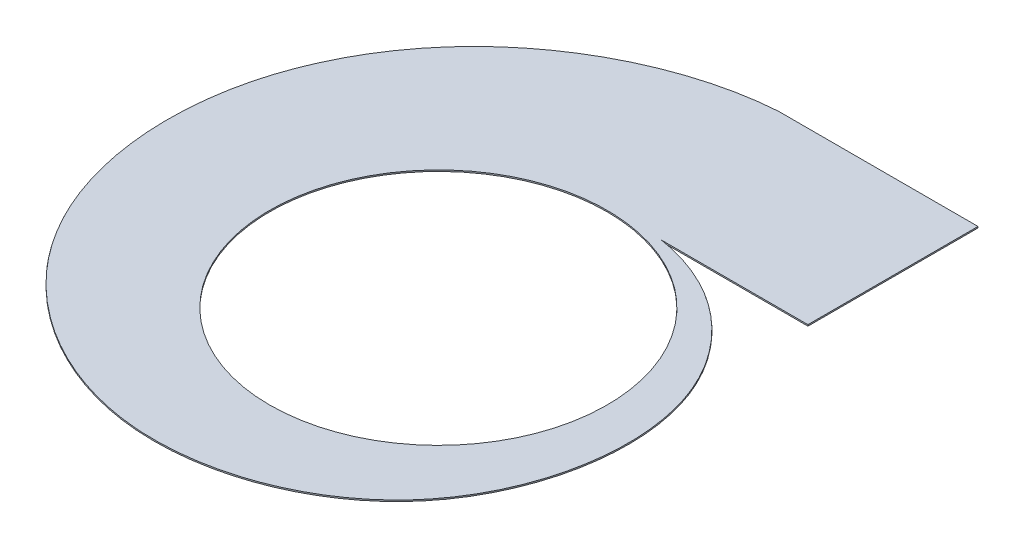
from build123d import *

# Parameters (mm, degrees)
SKETCH4_W               = 2
SKETCH4_H               = 200
BOSS_EXTRUDE1_DEPTH     = 2
SKETCH6_W               = 1405.005943927
SKETCH6_H               = 405.322926854
CUT_EXTRUDE1_DEPTH      = 315.996533231
CUT_EXTRUDE1_DEPTH_BACK = 440.29577895
SKETCH7_R               = 248
CUT_EXTRUDE2_DEPTH      = 10
SKETCH9_W               = 293.259068653
SKETCH9_H               = 250
BOSS_EXTRUDE3_DEPTH     = 2


with BuildPart() as part:
    # Sweep1: sweep along a curve in space
    with BuildLine() as sweep1_path:
        add(Edge.make_bspline(
            [(0, 0, -250), (8.181230869, 0, -251.302083333), (16.490485858, 0, -252.202239115), (33.283843215, 0, -253.165004898), (41.767918014, 0, -253.227597369), (58.825529276, 0, -252.489812839), (67.399036198, 0, -251.689421172), (84.546849552, 0, -249.209035813), (93.121124768, 0, -247.529030536), (110.179448676, 0, -243.28197111), (118.663464802, 0, -240.714908644), (135.448838644, 0, -234.695772919), (143.750162786, 0, -231.243694762), (160.077308396, 0, -223.466249466), (168.103095642, 0, -219.140880964), (183.786929167, 0, -209.638354886), (191.44494095, 0, -204.461199558), (206.302623467, 0, -193.286364859), (213.502259812, 0, -187.288691386), (227.355264371, 0, -174.513728488), (234.008598689, 0, -167.736448609), (246.684770924, 0, -153.452592355), (252.707575824, 0, -145.946029132), (264.043165005, 0, -130.262996352), (269.35591753, 0, -122.086543468), (279.197554898, 0, -105.131744499), (283.726409621, 0, -96.353418486), (291.933011092, 0, -78.270957675), (295.610729717, 0, -68.966846184), (302.055300528, 0, -49.916318794), (304.822126933, 0, -40.169929234), (309.39344656, 0, -20.325024564), (311.197916667, 0, -10.226538586), (313.802083333, 0, 10.226538586), (314.601759746, 0, 20.581098128), (315.163575101, 0, 41.445373487), (314.925697135, 0, 51.955055437), (313.389873123, 0, 73.024682105), (312.091913646, 0, 83.584591073), (308.424085306, 0, 104.646879334), (306.054206696, 0, 115.149221353), (300.241736515, 0, 135.986781136), (296.799139049, 0, 146.321960485), (288.851700557, 0, 166.714935063), (284.346857616, 0, 176.772691135), (274.29678815, 0, 196.501059175), (268.751563779, 0, 206.171631657), (256.653978741, 0, 225.017553673), (250.101624339, 0, 234.192863818), (236.034287727, 0, 251.943048248), (228.519315892, 0, 260.517883668), (212.582264503, 0, 276.965947186), (204.160199387, 0, 284.839137372), (186.475120704, 0, 299.787933778), (177.212125552, 0, 306.863503462), (157.921492035, 0, 320.127395411), (147.893875928, 0, 326.315682935), (127.159841084, 0, 337.722731058), (116.453448267, 0, 342.941459114), (94.45651255, 0, 352.335503566), (83.165999013, 0, 356.510790002), (60.103456218, 0, 363.753400295), (48.331459506, 0, 366.820697137), (24.415636833, 0, 371.79296719), (12.271846303, 0, 373.697916667), (-12.271846303, 0, 376.302083333), (-24.671710397, 0, 377.001280376), (-49.606903759, 0, 377.162145305), (-62.14219286, 0, 376.623796902), (-87.223834934, 0, 374.289933407), (-99.770145948, 0, 372.49440612), (-124.746909116, 0, 367.639134798), (-137.177317938, 0, 364.579382855), (-161.794113597, 0, 357.201501919), (-173.980456169, 0, 352.883369455), (-197.981031483, 0, 343.007628195), (-209.795219484, 0, 337.45002047), (-232.924809953, 0, 325.127326834), (-244.240167671, 0, 318.362246594), (-266.248178179, 0, 303.669602597), (-276.940786686, 0, 295.742049119), (-297.583473029, 0, 278.782210595), (-307.533507523, 0, 269.749940398), (-326.576630001, 0, 250.650800517), (-335.669676056, 0, 240.583950166), (-352.891096632, 0, 219.497649054), (-361.0194311, 0, 208.478221971), (-376.211625816, 0, 185.579987719), (-383.275448339, 0, 173.701208389), (-396.247907217, 0, 149.18793767), (-402.156508607, 0, 136.553478049), (-412.73799604, 0, 110.642067425), (-417.410850286, 0, 97.365151842), (-425.451500061, 0, 70.290593641), (-428.81926734, 0, 56.492989778), (-434.192487821, 0, 28.506249102), (-436.197916667, 0, 14.31715402), (-438.802083333, 0, -14.31715402), (-439.400801007, 0, -28.762322666), (-439.160715508, 0, -57.768434031), (-438.321896668, 0, -72.329330283), (-435.189993691, 0, -101.422987763), (-432.896898594, 0, -115.955700823), (-426.854184291, 0, -144.846938898), (-423.104559014, 0, -159.205414524), (-414.161267324, 0, -187.601446057), (-408.96759986, 0, -201.638951853), (-397.163555833, 0, -229.247127902), (-390.553183323, 0, -242.817747834), (-375.957865518, 0, -269.348560731), (-367.972929409, 0, -282.308703686), (-350.685226452, 0, -307.478802685), (-341.3824739, 0, -319.688709553), (-321.530133463, 0, -343.223897809), (-310.980564904, 0, -354.549131378), (-288.719336532, 0, -376.187312816), (-277.007700944, 0, -386.50021474), (-252.520177403, 0, -405.994259486), (-239.744318391, 0, -415.175358738), (-213.238483403, 0, -432.295856222), (-199.508540849, 0, -440.235213744), (-171.216034255, 0, -454.773083377), (-156.653507831, 0, -461.3715581), (-126.8276223, 0, -473.140488514), (-111.564304671, 0, -478.31091057), (-80.477731064, 0, -487.149599827), (-64.65452005, 0, -490.817837544), (-32.596861371, 0, -496.592008451), (-16.362461737, 0, -498.697916667), (0, 0, -500)],
            knots=[0, 0, 0, 0, 0.015625, 0.015625, 0.03125, 0.03125, 0.046875, 0.046875, 0.0625, 0.0625, 0.078125, 0.078125, 0.09375, 0.09375, 0.109375, 0.109375, 0.125, 0.125, 0.140625, 0.140625, 0.15625, 0.15625, 0.171875, 0.171875, 0.1875, 0.1875, 0.203125, 0.203125, 0.21875, 0.21875, 0.234375, 0.234375, 0.25, 0.25, 0.265625, 0.265625, 0.28125, 0.28125, 0.296875, 0.296875, 0.3125, 0.3125, 0.328125, 0.328125, 0.34375, 0.34375, 0.359375, 0.359375, 0.375, 0.375, 0.390625, 0.390625, 0.40625, 0.40625, 0.421875, 0.421875, 0.4375, 0.4375, 0.453125, 0.453125, 0.46875, 0.46875, 0.484375, 0.484375, 0.5, 0.5, 0.515625, 0.515625, 0.53125, 0.53125, 0.546875, 0.546875, 0.5625, 0.5625, 0.578125, 0.578125, 0.59375, 0.59375, 0.609375, 0.609375, 0.625, 0.625, 0.640625, 0.640625, 0.65625, 0.65625, 0.671875, 0.671875, 0.6875, 0.6875, 0.703125, 0.703125, 0.71875, 0.71875, 0.734375, 0.734375, 0.75, 0.75, 0.765625, 0.765625, 0.78125, 0.78125, 0.796875, 0.796875, 0.8125, 0.8125, 0.828125, 0.828125, 0.84375, 0.84375, 0.859375, 0.859375, 0.875, 0.875, 0.890625, 0.890625, 0.90625, 0.90625, 0.921875, 0.921875, 0.9375, 0.9375, 0.953125, 0.953125, 0.96875, 0.96875, 0.984375, 0.984375, 1, 1, 1, 1], degree=3))
    # Sketch4 → Sweep1 (sweep)
    with BuildSketch(Plane(origin=(0, 0, 0), x_dir=(0, 0, -1), z_dir=(1, 0, 0))):
        with Locations((249, 100)):
            Rectangle(SKETCH4_W, SKETCH4_H)
    sweep(path=sweep1_path.line, is_frenet=True)

    # Sketch5 → Boss-Extrude1 (add)
    with BuildSketch(Plane.XZ):
        with BuildLine():
            Line((0, -250), (0, -500))
            add(Edge.make_bspline(
                [(0, -500), (-121.735694783, -491.432273979), (-313.700359878, -396.441660701), (-452.526897535, -136.273127559), (-438.495522047, 84.543459016), (-316.9901671, 288.560325686), (-69.978911087, 425.75216419), (285.053092388, 296.782675329), (348.131054403, -49.507708763), (180.649502041, -235.122306433), (56.018270753, -259.081421157), (0, -250)],
                knots=[0, 0, 0, 0, 0.158819891, 0.2524484, 0.369226368, 0.425419464, 0.55694465, 0.698898779, 0.846399016, 0.926374082, 1, 1, 1, 1], degree=3))
        make_face()
    extrude(amount=BOSS_EXTRUDE1_DEPTH)

    # Sketch6 → Cut-Extrude1 (cut, two sides)
    with BuildSketch(Plane(origin=(0, 0, 0), x_dir=(0, 0, -1), z_dir=(1, 0, 0))) as cut_extrude1_sk:
        with Locations((51.908730168, 202.661463427)):
            Rectangle(SKETCH6_W, SKETCH6_H)
    extrude(amount=CUT_EXTRUDE1_DEPTH, mode=Mode.SUBTRACT)
    extrude(cut_extrude1_sk.sketch, amount=-CUT_EXTRUDE1_DEPTH_BACK, mode=Mode.SUBTRACT)

    # Sketch7 → Cut-Extrude2 (cut)
    with BuildSketch(Plane(origin=(0, 0, 0), x_dir=(1, 0, 0), z_dir=(0, 1, 0))):
        Circle(SKETCH7_R)
    extrude(amount=-CUT_EXTRUDE2_DEPTH, mode=Mode.SUBTRACT)

    # Sketch9 → Boss-Extrude3 (add)
    with BuildSketch(Plane(origin=(0, 0, 0), x_dir=(1, 0, 0), z_dir=(0, 1, 0))):
        with Locations((146.629534327, 375)):
            Rectangle(SKETCH9_W, SKETCH9_H)
    extrude(amount=-BOSS_EXTRUDE3_DEPTH)


solid = part.part
